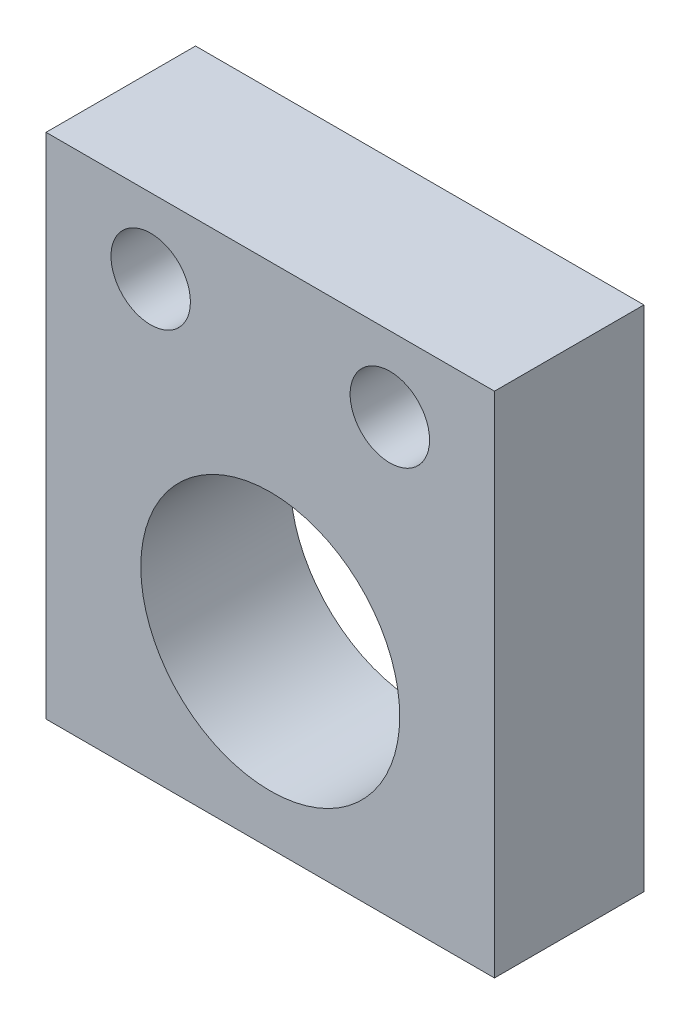
from build123d import *

# Parameters (mm, degrees)
SKETCH1_W                        = 38.1
SKETCH1_H                        = 43.18
BOSS_EXTRUDE1_DEPTH              = 12.7
SKETCH3_R                        = 11
CUT_EXTRUDE1_DEPTH               = 13.7
F_17_64_0_26563_DIAMETER_HOLE1_D = 6.747002


with BuildPart() as part:
    # Sketch1 → Boss-Extrude1 (new body)
    with BuildSketch(Plane.XY):
        with Locations((19.05, 21.59)):
            Rectangle(SKETCH1_W, SKETCH1_H)
    extrude(amount=-BOSS_EXTRUDE1_DEPTH)

    # Sketch3 → Cut-Extrude1 (cut, through all)
    with BuildSketch(Plane.XY):
        with Locations((19.05, 15.24)):
            Circle(SKETCH3_R)
    extrude(amount=-CUT_EXTRUDE1_DEPTH, mode=Mode.SUBTRACT)

    # 17/64 (0.26563) Diameter Hole1 (through all)
    with Locations(Plane(origin=(29.21, 36.83, 0), x_dir=(1, 0, 0), z_dir=(0, 0, 1))):
        with Locations((0, 0), (-20.32, 0)):
            Hole(F_17_64_0_26563_DIAMETER_HOLE1_D / 2)


solid = part.part
